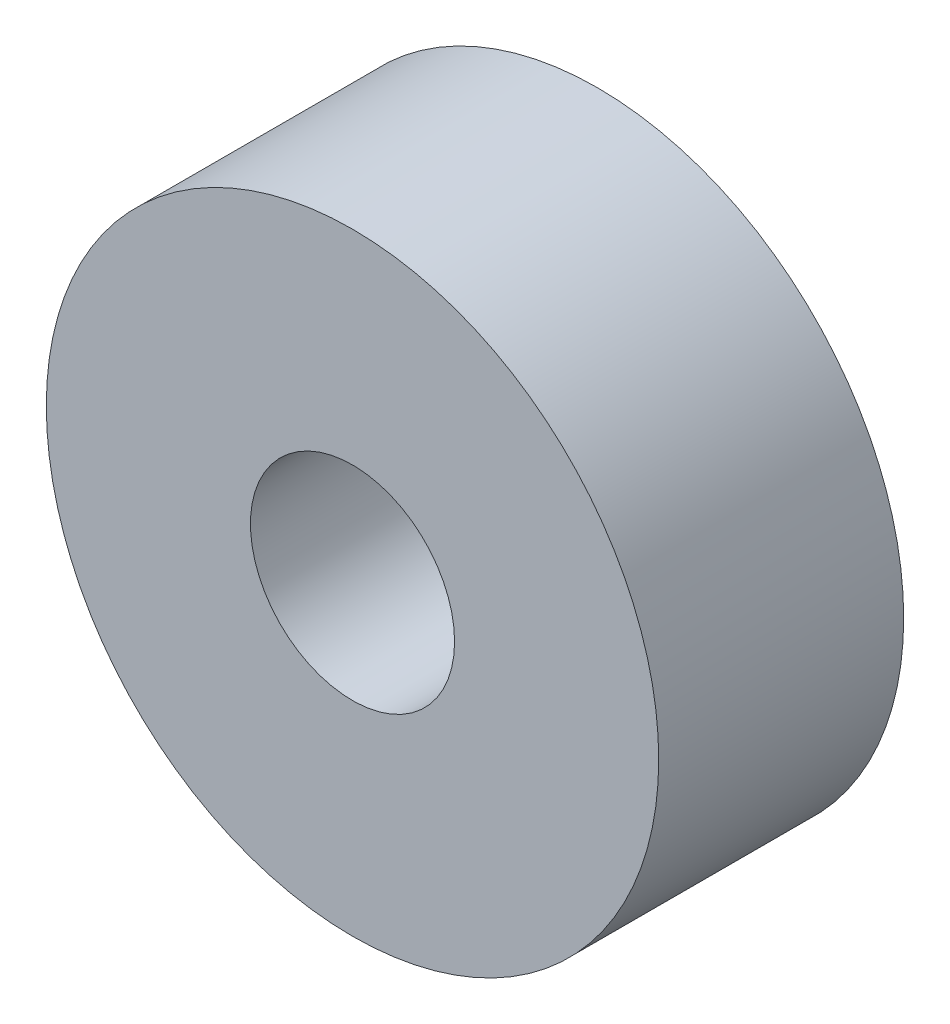
from build123d import *

# Parameters (mm, degrees)
SKETCH1_R           = 7.5
SKETCH1_R_2         = 2.5
BOSS_EXTRUDE1_DEPTH = 6


with BuildPart() as part:
    # Sketch1 → Boss-Extrude1 (new body)
    with BuildSketch(Plane.XY):
        Circle(SKETCH1_R)
        Circle(SKETCH1_R_2, mode=Mode.SUBTRACT)
    extrude(amount=BOSS_EXTRUDE1_DEPTH)


solid = part.part
